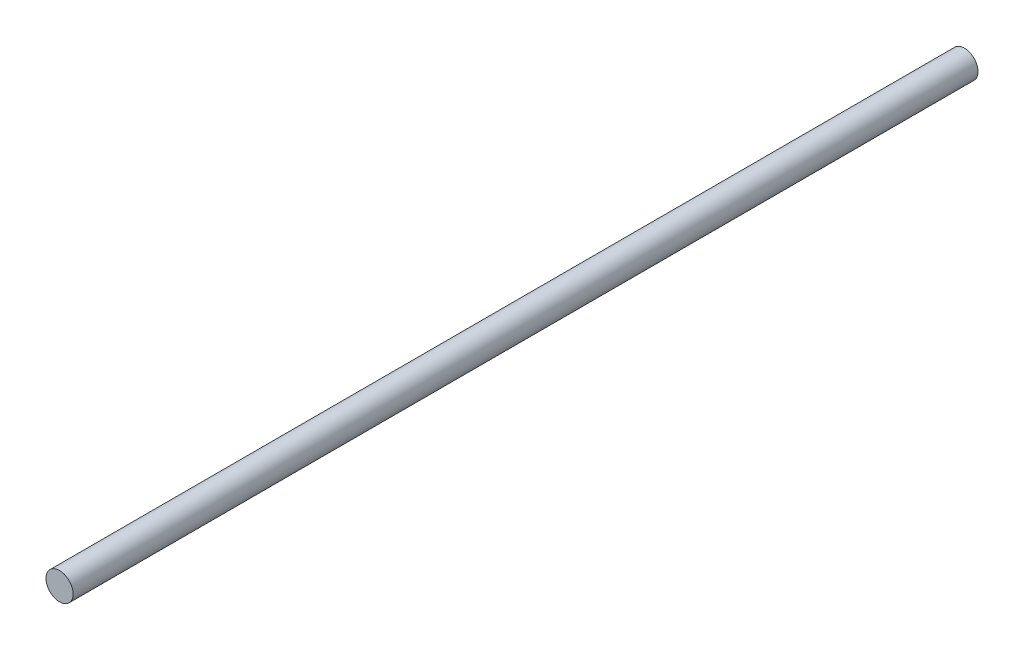
from build123d import *

# Parameters (mm, degrees)
EXTRUDE_1_DEPTH      = 100
EXTRUDE_1_DEPTH_BACK = 100
SKETCH_1_R           = 3


with BuildPart() as part:
    # Эскиз1 → Бобышка-Вытянуть1 (new, two sides: drawn at the far end of the back side and taken through both)
    with BuildSketch(Plane.XY.offset(-EXTRUDE_1_DEPTH_BACK)):
        Circle(SKETCH_1_R)
    extrude(amount=EXTRUDE_1_DEPTH + EXTRUDE_1_DEPTH_BACK)


solid = part.part
